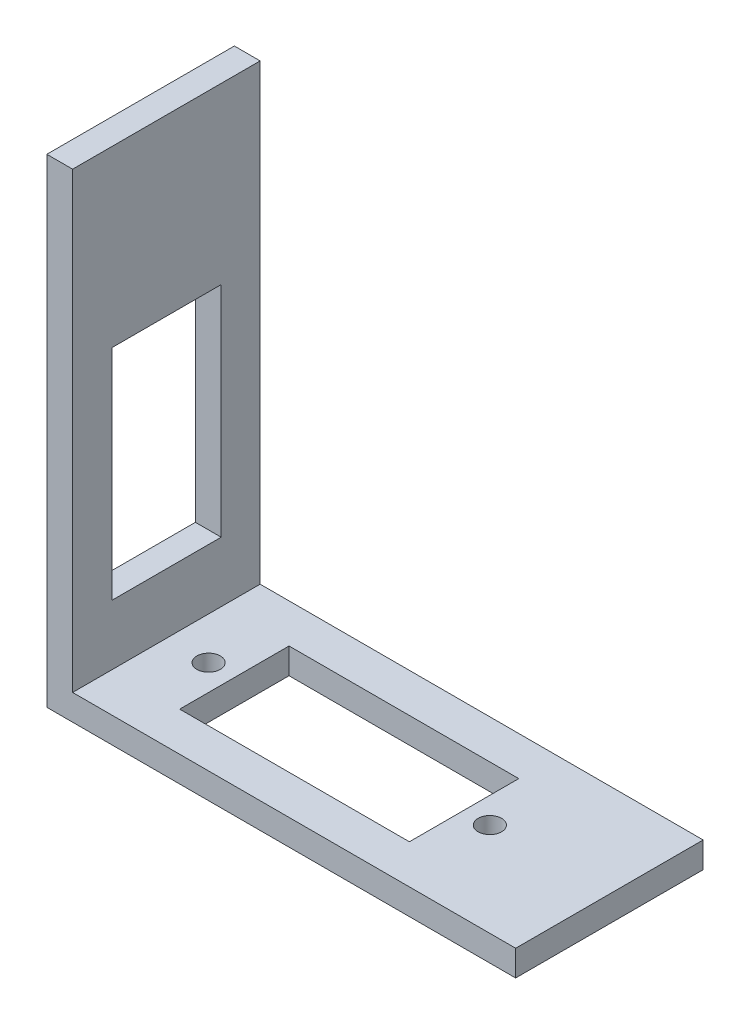
from build123d import *

# Parameters (mm, degrees)
SKETCH1_W           = 60
SKETCH1_H           = 24
BOSS_EXTRUDE1_DEPTH = 3.3
SKETCH2_W           = 3.3
SKETCH2_H           = 24
BOSS_EXTRUDE2_DEPTH = 61.3
SKETCH7_R           = 1.5
SKETCH7_W           = 29.4
SKETCH7_H           = 14
CUT_EXTRUDE4_DEPTH  = 3.3
SKETCH9_W           = 14
SKETCH9_H           = 28
CUT_EXTRUDE5_DEPTH  = 10


with BuildPart() as part:
    # Sketch1 → Boss-Extrude1 (new body)
    with BuildSketch(Plane(origin=(0, 0, 0), x_dir=(1, 0, 0), z_dir=(0, 1, 0))):
        Rectangle(SKETCH1_W, SKETCH1_H)
    extrude(amount=BOSS_EXTRUDE1_DEPTH)

    # Sketch2 → Boss-Extrude2 (add)
    with BuildSketch(Plane(origin=(0, 0, 0), x_dir=(1, 0, 0), z_dir=(0, 1, 0))):
        with Locations((-28.35, 0)):
            Rectangle(SKETCH2_W, SKETCH2_H)
    extrude(amount=BOSS_EXTRUDE2_DEPTH)

    # Sketch7 → Cut-Extrude4 (cut)
    with BuildSketch(Plane(origin=(0, 0, 0), x_dir=(1, 0, 0), z_dir=(0, 1, 0))):
        with Locations((-21.3, 0)):
            Circle(SKETCH7_R)
        with Locations((14.7, 0)):
            Circle(SKETCH7_R)
        with Locations((-3.3, 0)):
            Rectangle(SKETCH7_W, SKETCH7_H)
    extrude(amount=CUT_EXTRUDE4_DEPTH, mode=Mode.SUBTRACT)

    # Sketch9 → Cut-Extrude5 (cut)
    with BuildSketch(Plane.ZY.offset(30)):
        with Locations((-0.012794058, 25)):
            Rectangle(SKETCH9_W, SKETCH9_H)
    extrude(amount=-CUT_EXTRUDE5_DEPTH, mode=Mode.SUBTRACT)


solid = part.part
